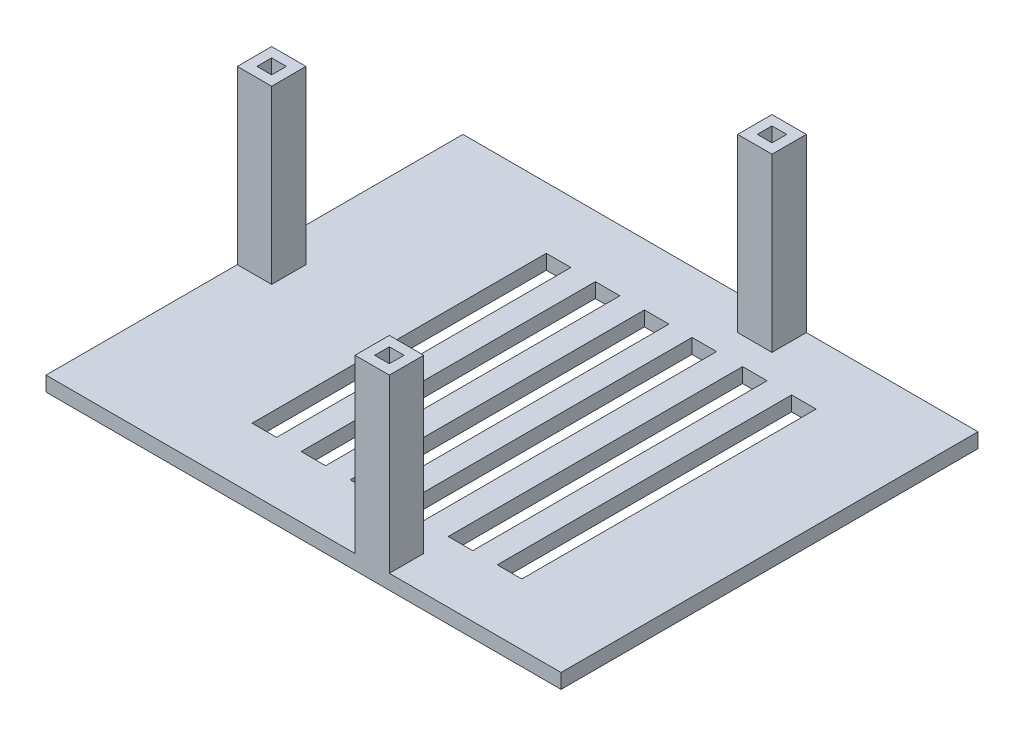
from build123d import *

# Parameters (mm, degrees)
SKETCH3_W           = 105
SKETCH3_H           = 85
BOSS_EXTRUDE3_DEPTH = 3
SKETCH5_W           = 7
SKETCH5_H           = 7
SKETCH5_W_2         = 3
SKETCH5_H_2         = 3
BOSS_EXTRUDE4_DEPTH = 35
SKETCH9_W           = 2.998895248
SKETCH9_H           = 2.995380601
BOSS_EXTRUDE5_DEPTH = 35
SKETCH11_W          = 7
SKETCH11_H          = 7
SKETCH11_W_2        = 3
SKETCH11_H_2        = 3
BOSS_EXTRUDE6_DEPTH = 35
CUT_EXTRUDE1_DEPTH  = 6
SKETCH14_W          = 5
SKETCH14_H          = 60
CUT_EXTRUDE3_DEPTH  = 33
SKETCH17_W          = 5
SKETCH17_H          = 60
CUT_EXTRUDE4_DEPTH  = 15


with BuildPart() as part:
    # Sketch3 → Boss-Extrude3 (new body)
    with BuildSketch(Plane(origin=(0, 0, 0), x_dir=(1, 0, 0), z_dir=(0, 1, 0))):
        with Locations((-2.316884661, -22.898810939)):
            Rectangle(SKETCH3_W, SKETCH3_H)
    extrude(amount=BOSS_EXTRUDE3_DEPTH)

    # Sketch5 → Boss-Extrude4 (add)
    with BuildSketch(Plane(origin=(0, 3, 0), x_dir=(1, 0, 0), z_dir=(0, 1, 0))):
        with Locations((11.683115339, -61.898810939)):
            Rectangle(SKETCH5_W, SKETCH5_H)
        with Locations((11.683115339, -61.898810939)):
            Rectangle(SKETCH5_W_2, SKETCH5_H_2, mode=Mode.SUBTRACT)
    extrude(amount=BOSS_EXTRUDE4_DEPTH)

    # Sketch9 → Boss-Extrude5 (add)
    with BuildSketch(Plane(origin=(0, 3, 0), x_dir=(1, 0, 0), z_dir=(0, 1, 0))):
        Polygon((15.183115339, 12.601189061), (15.183115339, 19.601189061), (8.183115339, 19.601189061), (8.183115339, 17.600348451), (8.183115339, 12.601189061), align=None)
        with Locations((11.687877227, 16.102658151)):
            Rectangle(SKETCH9_W, SKETCH9_H, mode=Mode.SUBTRACT)
    extrude(amount=BOSS_EXTRUDE5_DEPTH)

    # Sketch11 → Boss-Extrude6 (add)
    with BuildSketch(Plane(origin=(0, 3, 0), x_dir=(1, 0, 0), z_dir=(0, 1, 0))):
        with Locations((-51.316884661, -22.898810939)):
            Rectangle(SKETCH11_W, SKETCH11_H)
        with Locations((-51.316884661, -22.898810939)):
            Rectangle(SKETCH11_W_2, SKETCH11_H_2, mode=Mode.SUBTRACT)
    extrude(amount=BOSS_EXTRUDE6_DEPTH)

    # Sketch12 → Cut-Extrude1 (cut)
    with BuildSketch(Plane(origin=(0, 3, 0), x_dir=(1, 0, 0), z_dir=(0, 1, 0))):
        Polygon((29.683115339, -52.898810939), (29.683115339, -48.898810939), (29.683115339, 3.101189061), (29.683115339, 7.101189061), (24.683115339, 7.101189061), (24.683115339, -52.898810939), align=None)
    extrude(amount=-CUT_EXTRUDE1_DEPTH, mode=Mode.SUBTRACT)

    # Sketch14 → Cut-Extrude3 (cut)
    with BuildSketch(Plane(origin=(0, 3, 0), x_dir=(1, 0, 0), z_dir=(0, 1, 0))):
        with Locations((17.183115339, -22.898810939)):
            Rectangle(SKETCH14_W, SKETCH14_H)
        with Locations((-2.816884661, -22.898810939)):
            Rectangle(SKETCH14_W, SKETCH14_H)
        with Locations((-22.816884661, -22.898810939)):
            Rectangle(SKETCH14_W, SKETCH14_H)
        with Locations((-12.816884661, -22.898810939)):
            Rectangle(SKETCH14_W, SKETCH14_H)
    extrude(amount=-CUT_EXTRUDE3_DEPTH, mode=Mode.SUBTRACT)

    # Sketch17 → Cut-Extrude4 (cut)
    with BuildSketch(Plane(origin=(0, 3, 0), x_dir=(1, 0, 0), z_dir=(0, 1, 0))):
        with Locations((6.882849783, -22.898810939)):
            Rectangle(SKETCH17_W, SKETCH17_H)
    extrude(amount=-CUT_EXTRUDE4_DEPTH, mode=Mode.SUBTRACT)


solid = part.part
